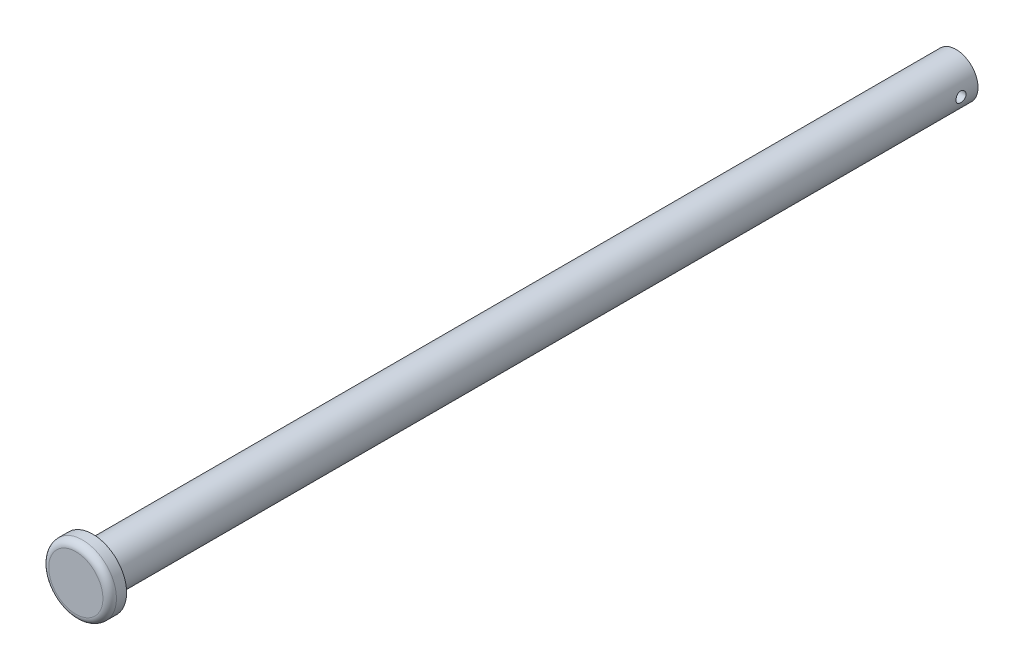
from build123d import *

# Parameters (mm, degrees)
SKETCH1_R               = 6.5
BOSS_EXTRUDE1_DEPTH     = 255
SKETCH2_R               = 10
BOSS_EXTRUDE2_DEPTH     = 5
FILLET1_R               = 2
SKETCH3_R               = 1.5
CUT_EXTRUDE1_DEPTH      = 11.0000001
CUT_EXTRUDE1_DEPTH_BACK = 11


with BuildPart() as part:
    # Sketch1 → Boss-Extrude1 (new body)
    with BuildSketch(Plane.XY):
        Circle(SKETCH1_R)
    extrude(amount=BOSS_EXTRUDE1_DEPTH)

    # Sketch2 → Boss-Extrude2 (add)
    with BuildSketch(Plane.XY.offset(255)):
        Circle(SKETCH2_R)
    extrude(amount=BOSS_EXTRUDE2_DEPTH)

    # Fillet1
    fillet1_edges = [part.edges().sort_by_distance(p)[0] for p in [
        (-6.5, 0, 255),
        (-10, 0, 260),
    ]]
    fillet(fillet1_edges, radius=FILLET1_R)

    # Sketch3 → Cut-Extrude1 (cut, two sides)
    with BuildSketch(Plane(origin=(0, 0, 0), x_dir=(0, 0, -1), z_dir=(1, 0, 0))) as cut_extrude1_sk:
        with Locations((-5, 0)):
            Circle(SKETCH3_R)
    extrude(amount=CUT_EXTRUDE1_DEPTH, mode=Mode.SUBTRACT)
    extrude(cut_extrude1_sk.sketch, amount=-CUT_EXTRUDE1_DEPTH_BACK, mode=Mode.SUBTRACT)


solid = part.part
